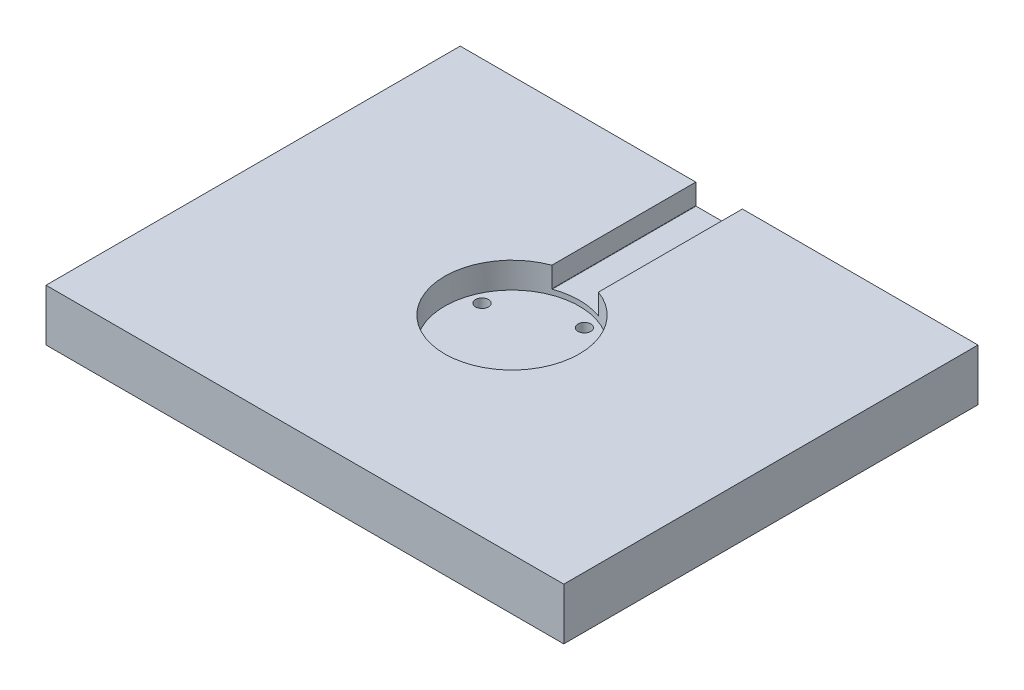
from build123d import *

# Parameters (mm, degrees)
SKETCH1_W                 = 200
SKETCH1_H                 = 160
BASE_DEPTH                = 20
SKETCH2_R                 = 26
LOAD_CELL_CUT_DEPTH       = 10
CUT_WIRE_REACH            = 162
SKETCH6_W                 = 18
SKETCH6_H                 = 8
FILLET6_R                 = 0.1
F_5_0MM_DOWEL_HOLE1_D     = 5
F_5_0MM_DOWEL_HOLE1_DEPTH = 10


with BuildPart() as part:
    # Sketch1 → base (new body)
    with BuildSketch(Plane(origin=(0, 0, 0), x_dir=(1, 0, 0), z_dir=(0, 1, 0))):
        Rectangle(SKETCH1_W, SKETCH1_H)
    extrude(amount=BASE_DEPTH)

    # Sketch2 → load cell cut (cut)
    with BuildSketch(Plane(origin=(0, 20, 0), x_dir=(1, 0, 0), z_dir=(0, 1, 0))):
        Circle(SKETCH2_R)
    extrude(amount=-LOAD_CELL_CUT_DEPTH, mode=Mode.SUBTRACT)

    # Sketch6 → cut wire (cut, up to next)
    with BuildSketch(Plane.XY.offset(-80), mode=Mode.PRIVATE) as cut_wire_sk1:
        with Locations((0, 16)):
            Rectangle(SKETCH6_W, SKETCH6_H)
    cut_wire_tool1 = extrude(cut_wire_sk1.sketch, amount=CUT_WIRE_REACH, mode=Mode.PRIVATE) & part.part
    add(cut_wire_tool1.solids().sort_by_distance((0, 16, -80))[0], mode=Mode.SUBTRACT)

    # Fillet6
    fillet6_edges = [part.edges().sort_by_distance(p)[0] for p in [
        (9, 12, -52.196310918),
        (-9, 12, -52.196310918),
    ]]
    fillet(fillet6_edges, radius=FILLET6_R)

    # Ø5.0mm Dowel Hole1
    with Locations(Plane(origin=(-8.189425453, 0, 19.771021996), x_dir=(0, 0, -1), z_dir=(0, -1, 0))):
        with Locations((0, 0), (11.581596543, 27.960447449), (39.542043992, 16.378850906), (27.960447449, -11.581596543)):
            Hole(F_5_0MM_DOWEL_HOLE1_D / 2, depth=F_5_0MM_DOWEL_HOLE1_DEPTH)


solid = part.part
